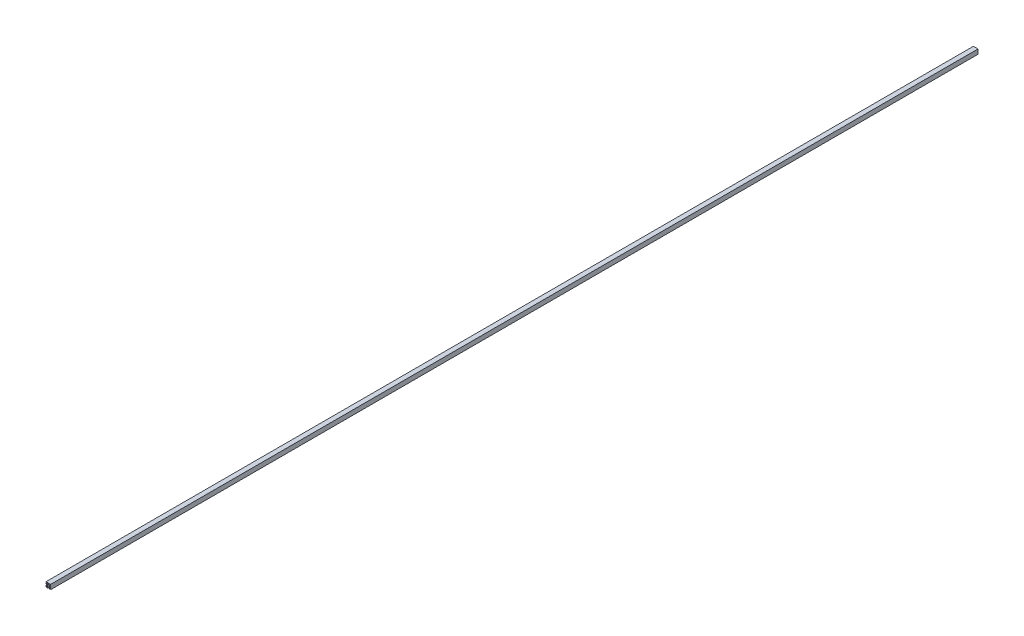
from build123d import *

# Parameters (mm, degrees)
SKETCH1_R          = 6.05
SKETCH1_W          = 4.5
SKETCH1_H          = 4.5
EXTRUDE1_DEPTH     = 6000
CUT_EXTRUDE1_DEPTH = 6001


with BuildPart() as part:
    # Sketch1 → Extrude1 (new body)
    with BuildSketch(Plane.XY):
        Polygon((15, -14.99999999), (13.499999971, -14.99999999), (13.499999971, -7.49999999), (12.70000011, -7.49999999), (11.534230832, -9.99999999), (10.300000176, -9.99999999), (9.399999971, -11.93005553), (9.399999971, -15), (4, -15), (4, -13), (7.265685, -13), (7.265685, -11.63431525), (3.931371213, -8.3), (-3.931371213, -8.3), (-7.265685, -11.63431525), (-7.265685, -13), (-4, -13), (-4, -15), (-15, -15), (-15, -4), (-13, -4), (-13, -7.265685), (-11.63431525, -7.265685), (-8.3, -3.931371213), (-8.3, 3.931371213), (-11.63431525, 7.265685), (-13, 7.265685), (-13, 4), (-15, 4), (-15, 9.399999971), (-11.93005553, 9.399999971), (-9.99999999, 10.300000176), (-9.99999999, 11.534230832), (-7.49999999, 12.70000011), (-7.49999999, 13.499999971), (-14.999999992, 13.499999971), (-14.999999992, 15), (15, 15), align=None)
        Circle(SKETCH1_R, mode=Mode.SUBTRACT)
        Polygon((10.57862485, -8.5), (9.344395021, -8.5), (8.361187544, -10.60849553), (5.176238259, -7.423547516), (8.376249722, -3.426503268), (7.55, -2.600251667), (7.55, 2.600251667), (8.376249722, 3.426503268), (6.175454615, 6.175454615), (3.426503268, 8.376249722), (2.600251667, 7.55), (-2.600251667, 7.55), (-3.426503268, 8.376249722), (-7.423547516, 5.176238259), (-10.60849553, 8.361187544), (-8.5, 9.344395021), (-8.5, 10.57862485), (-6, 11.7443949), (-6, 13.5), (13.5, 13.5), (13.5, -6), (11.7443949, -6), align=None, mode=Mode.SUBTRACT)
        with Locations((-11.25, -11.25)):
            Rectangle(SKETCH1_W, SKETCH1_H, mode=Mode.SUBTRACT)
    extrude(amount=-EXTRUDE1_DEPTH)

    # Sketch2 → Cut-Extrude1 (cut, through all)
    with BuildSketch(Plane.XY):
        Polygon((-11.25, -9), (-7.77480438, -5.52686047), (-5.52480438, -7.77686047), (-9, -11.25), align=None)
    extrude(amount=-CUT_EXTRUDE1_DEPTH, mode=Mode.SUBTRACT)


solid = part.part
